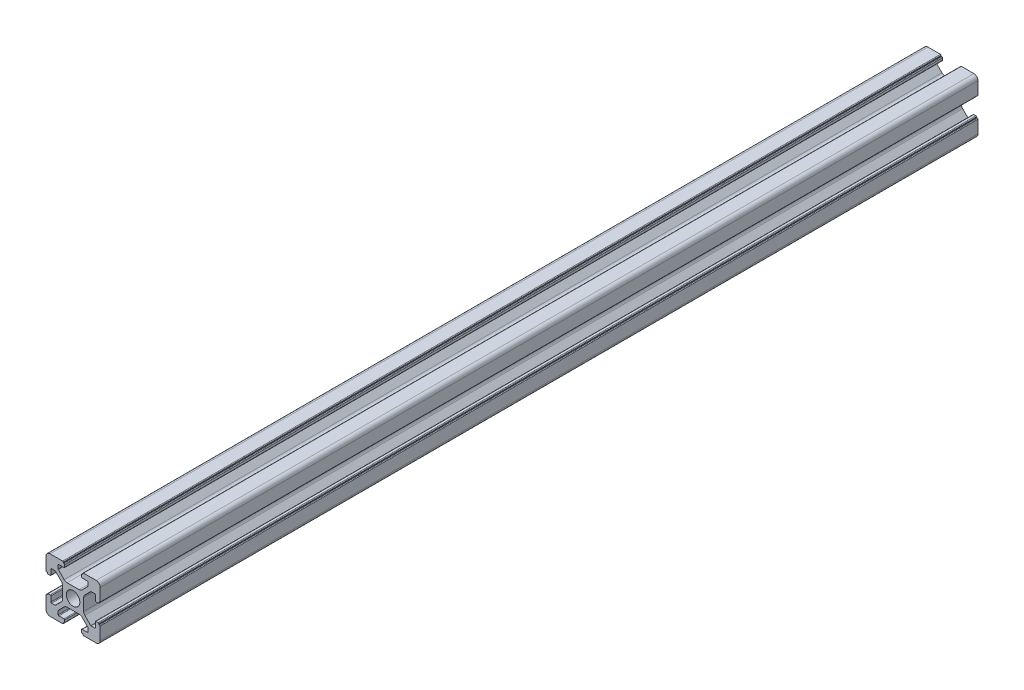
from build123d import *

# Parameters (mm, degrees)
SKETCH_1_R      = 2.5
EXTRUDE_1_DEPTH = 324


with BuildPart() as part:
    # 草图1 → 凸台-拉伸1 (new body)
    with BuildSketch(Plane.XY):
        with BuildLine():
            Line((-8.502261885, -10.002261885), (-3.85, -10.002261885))
            ThreePointArc((-3.85, -10.002261885), (-3.673223305, -9.929038581), (-3.6, -9.752261885))
            Line((-3.6, -9.752261885), (-3.6, -9.502261885))
            Line((-3.6, -9.502261885), (-3.35, -9.502261885))
            ThreePointArc((-3.35, -9.502261885), (-3.173223305, -9.429038581), (-3.1, -9.252261885))
            Line((-3.1, -9.252261885), (-3.1, -8.45))
            ThreePointArc((-3.1, -8.45), (-3.173223305, -8.273223305), (-3.35, -8.2))
            Line((-3.35, -8.2), (-5.25, -8.2))
            ThreePointArc((-5.25, -8.2), (-5.426776695, -8.126776695), (-5.5, -7.95))
            Line((-5.5, -7.95), (-5.5, -6.664213562))
            ThreePointArc((-5.5, -6.664213562), (-5.480969883, -6.568542704), (-5.426776695, -6.487436867))
            Line((-5.426776695, -6.487436867), (-3.278679656, -4.339339828))
            ThreePointArc((-3.278679656, -4.339339828), (-2.792044633, -4.014180701), (-2.218019485, -3.9))
            Line((-2.218019485, -3.9), (2.218019485, -3.9))
            ThreePointArc((2.218019485, -3.9), (2.792044633, -4.014180701), (3.278679656, -4.339339828))
            Line((3.278679656, -4.339339828), (5.426776695, -6.487436867))
            ThreePointArc((5.426776695, -6.487436867), (5.480969883, -6.568542704), (5.5, -6.664213562))
            Line((5.5, -6.664213562), (5.5, -7.95))
            ThreePointArc((5.5, -7.95), (5.426776695, -8.126776695), (5.25, -8.2))
            Line((5.25, -8.2), (3.35, -8.2))
            ThreePointArc((3.35, -8.2), (3.173223305, -8.273223305), (3.1, -8.45))
            Line((3.1, -8.45), (3.1, -9.252261885))
            ThreePointArc((3.1, -9.252261885), (3.173223305, -9.429038581), (3.35, -9.502261885))
            Line((3.35, -9.502261885), (3.6, -9.502261885))
            Line((3.6, -9.502261885), (3.6, -9.752261885))
            ThreePointArc((3.6, -9.752261885), (3.673223305, -9.929038581), (3.85, -10.002261885))
            Line((3.85, -10.002261885), (8.502261885, -10.002261885))
            ThreePointArc((8.502261885, -10.002261885), (9.562922057, -9.562922057), (10.002261885, -8.502261885))
            Line((10.002261885, -8.502261885), (10.002261885, -3.85))
            ThreePointArc((10.002261885, -3.85), (9.929038581, -3.673223305), (9.752261885, -3.6))
            Line((9.752261885, -3.6), (9.502261885, -3.6))
            Line((9.502261885, -3.6), (9.502261885, -3.35))
            ThreePointArc((9.502261885, -3.35), (9.429038581, -3.173223305), (9.252261885, -3.1))
            Line((9.252261885, -3.1), (8.45, -3.1))
            ThreePointArc((8.45, -3.1), (8.273223305, -3.173223305), (8.2, -3.35))
            Line((8.2, -3.35), (8.2, -5.25))
            ThreePointArc((8.2, -5.25), (8.126776695, -5.426776695), (7.95, -5.5))
            Line((7.95, -5.5), (6.664213562, -5.5))
            ThreePointArc((6.664213562, -5.5), (6.568542704, -5.480969883), (6.487436867, -5.426776695))
            Line((6.487436867, -5.426776695), (4.339339828, -3.278679656))
            ThreePointArc((4.339339828, -3.278679656), (4.014180701, -2.792044633), (3.9, -2.218019485))
            Line((3.9, -2.218019485), (3.9, 2.218019485))
            ThreePointArc((3.9, 2.218019485), (4.014180701, 2.792044633), (4.339339828, 3.278679656))
            Line((4.339339828, 3.278679656), (6.487436867, 5.426776695))
            ThreePointArc((6.487436867, 5.426776695), (6.568542704, 5.480969883), (6.664213562, 5.5))
            Line((6.664213562, 5.5), (7.95, 5.5))
            ThreePointArc((7.95, 5.5), (8.126776695, 5.426776695), (8.2, 5.25))
            Line((8.2, 5.25), (8.2, 3.35))
            ThreePointArc((8.2, 3.35), (8.273223305, 3.173223305), (8.45, 3.1))
            Line((8.45, 3.1), (9.252261885, 3.1))
            ThreePointArc((9.252261885, 3.1), (9.429038581, 3.173223305), (9.502261885, 3.35))
            Line((9.502261885, 3.35), (9.502261885, 3.6))
            Line((9.502261885, 3.6), (9.752261885, 3.6))
            ThreePointArc((9.752261885, 3.6), (9.929038581, 3.673223305), (10.002261885, 3.85))
            Line((10.002261885, 3.85), (10.002261885, 8.502261885))
            ThreePointArc((10.002261885, 8.502261885), (9.562922057, 9.562922057), (8.502261885, 10.002261885))
            Line((8.502261885, 10.002261885), (3.85, 10.002261885))
            ThreePointArc((3.85, 10.002261885), (3.673223305, 9.929038581), (3.6, 9.752261885))
            Line((3.6, 9.752261885), (3.6, 9.502261885))
            Line((3.6, 9.502261885), (3.35, 9.502261885))
            ThreePointArc((3.35, 9.502261885), (3.173223305, 9.429038581), (3.1, 9.252261885))
            Line((3.1, 9.252261885), (3.1, 8.45))
            ThreePointArc((3.1, 8.45), (3.173223305, 8.273223305), (3.35, 8.2))
            Line((3.35, 8.2), (5.25, 8.2))
            ThreePointArc((5.25, 8.2), (5.426776695, 8.126776695), (5.5, 7.95))
            Line((5.5, 7.95), (5.5, 6.664213562))
            ThreePointArc((5.5, 6.664213562), (5.480969883, 6.568542704), (5.426776695, 6.487436867))
            Line((5.426776695, 6.487436867), (3.278679656, 4.339339828))
            ThreePointArc((3.278679656, 4.339339828), (2.792044633, 4.014180701), (2.218019485, 3.9))
            Line((2.218019485, 3.9), (-2.218019485, 3.9))
            ThreePointArc((-2.218019485, 3.9), (-2.792044633, 4.014180701), (-3.278679656, 4.339339828))
            Line((-3.278679656, 4.339339828), (-5.426776695, 6.487436867))
            ThreePointArc((-5.426776695, 6.487436867), (-5.480969883, 6.568542704), (-5.5, 6.664213562))
            Line((-5.5, 6.664213562), (-5.5, 7.95))
            ThreePointArc((-5.5, 7.95), (-5.426776695, 8.126776695), (-5.25, 8.2))
            Line((-5.25, 8.2), (-3.35, 8.2))
            ThreePointArc((-3.35, 8.2), (-3.173223305, 8.273223305), (-3.1, 8.45))
            Line((-3.1, 8.45), (-3.1, 9.252261885))
            ThreePointArc((-3.1, 9.252261885), (-3.173223305, 9.429038581), (-3.35, 9.502261885))
            Line((-3.35, 9.502261885), (-3.6, 9.502261885))
            Line((-3.6, 9.502261885), (-3.6, 9.752261885))
            ThreePointArc((-3.6, 9.752261885), (-3.673223305, 9.929038581), (-3.85, 10.002261885))
            Line((-3.85, 10.002261885), (-8.502261885, 10.002261885))
            ThreePointArc((-8.502261885, 10.002261885), (-9.562922057, 9.562922057), (-10.002261885, 8.502261885))
            Line((-10.002261885, 8.502261885), (-10.002261885, 3.85))
            ThreePointArc((-10.002261885, 3.85), (-9.929038581, 3.673223305), (-9.752261885, 3.6))
            Line((-9.752261885, 3.6), (-9.502261885, 3.6))
            Line((-9.502261885, 3.6), (-9.502261885, 3.35))
            ThreePointArc((-9.502261885, 3.35), (-9.429038581, 3.173223305), (-9.252261885, 3.1))
            Line((-9.252261885, 3.1), (-8.45, 3.1))
            ThreePointArc((-8.45, 3.1), (-8.273223305, 3.173223305), (-8.2, 3.35))
            Line((-8.2, 3.35), (-8.2, 5.25))
            ThreePointArc((-8.2, 5.25), (-8.126776695, 5.426776695), (-7.95, 5.5))
            Line((-7.95, 5.5), (-6.664213562, 5.5))
            ThreePointArc((-6.664213562, 5.5), (-6.568542704, 5.480969883), (-6.487436867, 5.426776695))
            Line((-6.487436867, 5.426776695), (-4.339339828, 3.278679656))
            ThreePointArc((-4.339339828, 3.278679656), (-4.014180701, 2.792044633), (-3.9, 2.218019485))
            Line((-3.9, 2.218019485), (-3.9, -2.218019485))
            ThreePointArc((-3.9, -2.218019485), (-4.014180701, -2.792044633), (-4.339339828, -3.278679656))
            Line((-4.339339828, -3.278679656), (-6.487436867, -5.426776695))
            ThreePointArc((-6.487436867, -5.426776695), (-6.568542704, -5.480969883), (-6.664213562, -5.5))
            Line((-6.664213562, -5.5), (-7.95, -5.5))
            ThreePointArc((-7.95, -5.5), (-8.126776695, -5.426776695), (-8.2, -5.25))
            Line((-8.2, -5.25), (-8.2, -3.35))
            ThreePointArc((-8.2, -3.35), (-8.273223305, -3.173223305), (-8.45, -3.1))
            Line((-8.45, -3.1), (-9.252261885, -3.1))
            ThreePointArc((-9.252261885, -3.1), (-9.429038581, -3.173223305), (-9.502261885, -3.35))
            Line((-9.502261885, -3.35), (-9.502261885, -3.6))
            Line((-9.502261885, -3.6), (-9.752261885, -3.6))
            ThreePointArc((-9.752261885, -3.6), (-9.929038581, -3.673223305), (-10.002261885, -3.85))
            Line((-10.002261885, -3.85), (-10.002261885, -8.502261885))
            ThreePointArc((-10.002261885, -8.502261885), (-9.562922057, -9.562922057), (-8.502261885, -10.002261885))
        make_face()
        Circle(SKETCH_1_R, mode=Mode.SUBTRACT)
    extrude(amount=EXTRUDE_1_DEPTH)


solid = part.part
